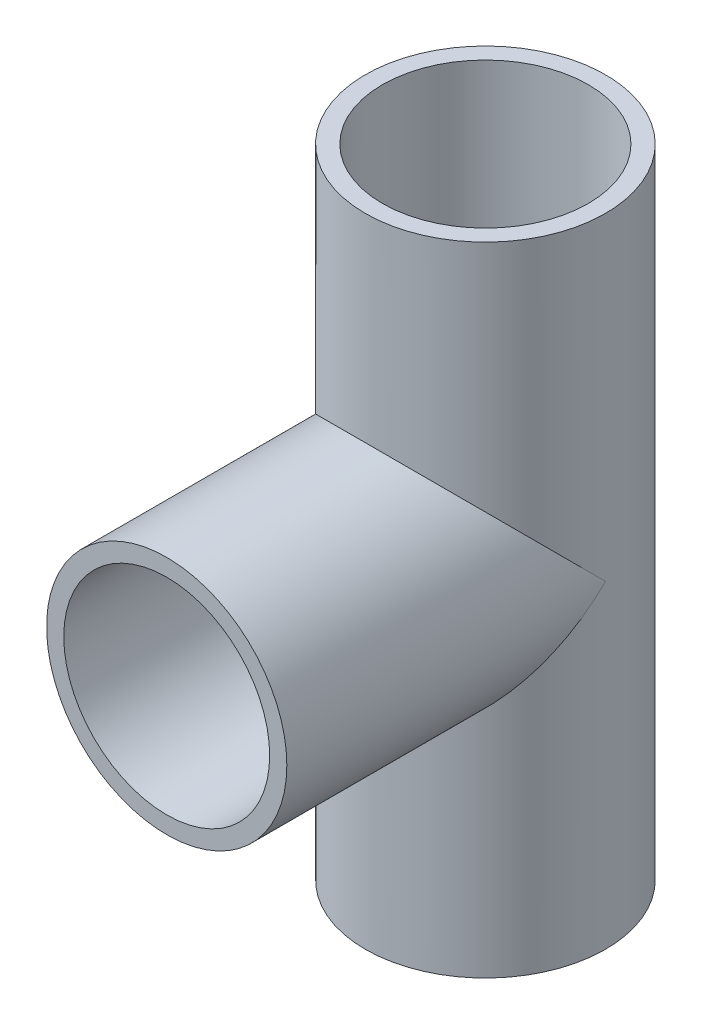
from build123d import *

# Parameters (mm, degrees)
SKETCH1_R           = 24.5
SKETCH1_R_2         = 21
BOSS_EXTRUDE1_DEPTH = 130
SKETCH3_R           = 24.5
SKETCH3_R_2         = 21
BOSS_EXTRUDE2_DEPTH = 65


with BuildPart() as part:
    # Sketch1 → Boss-Extrude1 (new body)
    with BuildSketch(Plane(origin=(0, 0, 0), x_dir=(1, 0, 0), z_dir=(0, 1, 0))):
        Circle(SKETCH1_R)
        Circle(SKETCH1_R_2, mode=Mode.SUBTRACT)
    extrude(amount=BOSS_EXTRUDE1_DEPTH)

    # Sketch3 → Boss-Extrude2 (add)
    with BuildSketch(Plane.XY):
        with Locations((0, 65)):
            Circle(SKETCH3_R)
        with Locations((0, 65)):
            Circle(SKETCH3_R_2, mode=Mode.SUBTRACT)
    extrude(amount=BOSS_EXTRUDE2_DEPTH)


solid = part.part
